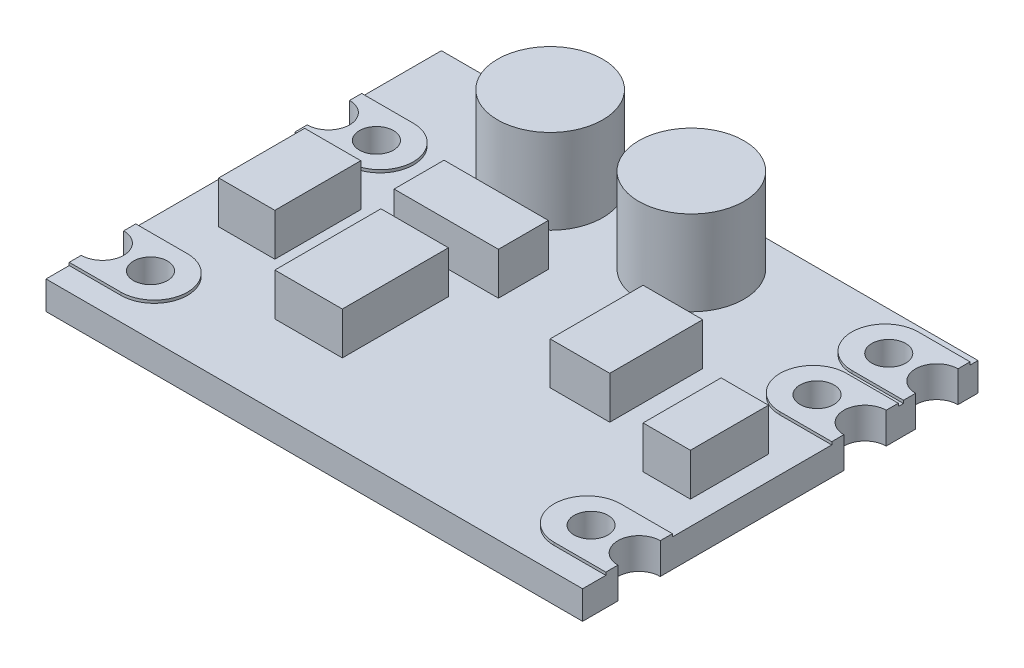
from build123d import *

# Parameters (mm, degrees)
SKETCH_1_W          = 19
SKETCH_1_H          = 14
EXTRUDE_1_DEPTH     = 1
SKETCH_2_R          = 0.75
SKETCH_2_R_2        = 0.602396592
CUT_EXTRUDE_1_DEPTH = 2
SKETCH_4_R          = 1.862700745
EXTRUDE_2_DEPTH     = 3
SKETCH_3_R          = 0.602396592
EXTRUDE_3_DEPTH     = 0.1
SKETCH_5_W          = 2.390465956
SKETCH_5_H          = 3.756446502
SKETCH_5_W_2        = 2.111060845
SKETCH_5_H_2        = 3.290771316
SKETCH_5_W_3        = 1.986880794
SKETCH_5_H_3        = 3.042411217
SKETCH_5_W_4        = 3.694356478
SKETCH_5_H_4        = 1.769565707
SKETCH_5_W_5        = 1.676430671
SKETCH_5_H_5        = 2.763006106
EXTRUDE_4_DEPTH     = 1.5


with BuildPart() as part:
    # Эскиз1 → Бобышка-Вытянуть1 (new body)
    with BuildSketch(Plane(origin=(0, 0, 0), x_dir=(1, 0, 0), z_dir=(0, 1, 0))):
        Rectangle(SKETCH_1_W, SKETCH_1_H)
    extrude(amount=EXTRUDE_1_DEPTH)

    # Эскиз2 → Вырез-Вытянуть1 (cut, through all)
    with BuildSketch(Plane(origin=(0, 1, 0), x_dir=(1, 0, 0), z_dir=(0, 1, 0))):
        with Locations((-9.5, -5)):
            Circle(SKETCH_2_R)
        with Locations((-9.5, 3)):
            Circle(SKETCH_2_R)
        with Locations((9.5, 3)):
            Circle(SKETCH_2_R)
        with Locations((9.5, -5)):
            Circle(SKETCH_2_R)
        with Locations((9.5, 5.54)):
            Circle(SKETCH_2_R)
        with Locations((-7.8, 3)):
            Circle(SKETCH_2_R_2)
        with Locations((-7.8, -5)):
            Circle(SKETCH_2_R_2)
        with Locations((7.8, 3)):
            Circle(SKETCH_2_R_2)
        with Locations((7.8, -5)):
            Circle(SKETCH_2_R_2)
        with Locations((7.8, 5.54)):
            Circle(SKETCH_2_R_2)
    extrude(amount=-CUT_EXTRUDE_1_DEPTH, mode=Mode.SUBTRACT)

    # Эскиз4 → Бобышка-Вытянуть2 (add)
    with BuildSketch(Plane(origin=(0, 1, 0), x_dir=(1, 0, 0), z_dir=(0, 1, 0))):
        with Locations((-3.383906354, 4.734364394)):
            Circle(SKETCH_4_R)
        with Locations((1.616093646, 4.734364394)):
            Circle(SKETCH_4_R)
    extrude(amount=EXTRUDE_2_DEPTH)

    # Эскиз3 → Бобышка-Вытянуть3 (add)
    with BuildSketch(Plane(origin=(0, 1, 0), x_dir=(1, 0, 0), z_dir=(0, 1, 0))):
        with BuildLine():
            Line((-7.668118067, -3.821776661), (-9.5, -3.821776661))
            Line((-9.5, -3.821776661), (-9.5, -4.25))
            ThreePointArc((-9.5, -4.25), (-8.75, -5), (-9.5, -5.75))
            Line((-9.5, -5.75), (-9.5, -6.178223339))
            Line((-9.5, -6.178223339), (-7.668118067, -6.178223339))
            ThreePointArc((-7.668118067, -6.178223339), (-6.489894728, -5), (-7.668118067, -3.821776661))
        make_face()
        with Locations((-7.8, -5)):
            Circle(SKETCH_3_R, mode=Mode.SUBTRACT)
        with BuildLine():
            Line((-9.5, 2.25), (-9.5, 1.821776661))
            Line((-9.5, 1.821776661), (-7.668118067, 1.821776661))
            ThreePointArc((-7.668118067, 1.821776661), (-6.489894728, 3), (-7.668118067, 4.178223339))
            Line((-7.668118067, 4.178223339), (-9.5, 4.178223339))
            Line((-9.5, 4.178223339), (-9.5, 3.75))
            ThreePointArc((-9.5, 3.75), (-8.75, 3), (-9.5, 2.25))
        make_face()
        with Locations((-7.8, 3)):
            Circle(SKETCH_3_R, mode=Mode.SUBTRACT)
        with BuildLine():
            Line((7.668118067, -6.178223339), (9.5, -6.178223339))
            Line((9.5, -6.178223339), (9.5, -5.75))
            ThreePointArc((9.5, -5.75), (8.75, -5), (9.5, -4.25))
            Line((9.5, -4.25), (9.5, -3.821776661))
            Line((9.5, -3.821776661), (7.668118067, -3.821776661))
            ThreePointArc((7.668118067, -3.821776661), (6.489894728, -5), (7.668118067, -6.178223339))
        make_face()
        with Locations((7.8, -5)):
            Circle(SKETCH_3_R, mode=Mode.SUBTRACT)
        with BuildLine():
            Line((9.5, 6.29), (9.5, 6.718223339))
            Line((9.5, 6.718223339), (7.668118067, 6.718223339))
            ThreePointArc((7.668118067, 6.718223339), (6.489894728, 5.54), (7.668118067, 4.361776661))
            Line((7.668118067, 4.361776661), (9.5, 4.361776661))
            Line((9.5, 4.361776661), (9.5, 4.79))
            ThreePointArc((9.5, 4.79), (8.75, 5.54), (9.5, 6.29))
        make_face()
        with Locations((7.8, 5.54)):
            Circle(SKETCH_3_R, mode=Mode.SUBTRACT)
        with BuildLine():
            Line((7.668118067, 1.821776661), (9.5, 1.821776661))
            Line((9.5, 1.821776661), (9.5, 2.25))
            ThreePointArc((9.5, 2.25), (8.75, 3), (9.5, 3.75))
            Line((9.5, 3.75), (9.5, 4.178223339))
            Line((9.5, 4.178223339), (7.668118067, 4.178223339))
            ThreePointArc((7.668118067, 4.178223339), (6.489894728, 3), (7.668118067, 1.821776661))
        make_face()
        with Locations((7.8, 3)):
            Circle(SKETCH_3_R, mode=Mode.SUBTRACT)
    extrude(amount=EXTRUDE_3_DEPTH)

    # Эскиз5 → Бобышка-Вытянуть4 (add)
    with BuildSketch(Plane(origin=(0, 1, 0), x_dir=(1, 0, 0), z_dir=(0, 1, 0))):
        with Locations((-3.026888711, -2.297330919)):
            Rectangle(SKETCH_5_W, SKETCH_5_H)
        with Locations((3.818536528, 0.232837593)):
            Rectangle(SKETCH_5_W_2, SKETCH_5_H_2)
        with Locations((-7.047217819, -0.82269283)):
            Rectangle(SKETCH_5_W_3, SKETCH_5_H_3)
        with Locations((-2.747483599, 1.303890522)):
            Rectangle(SKETCH_5_W_4, SKETCH_5_H_4)
        with Locations((7.82334313, -0.962395385)):
            Rectangle(SKETCH_5_W_5, SKETCH_5_H_5)
    extrude(amount=EXTRUDE_4_DEPTH)


solid = part.part
